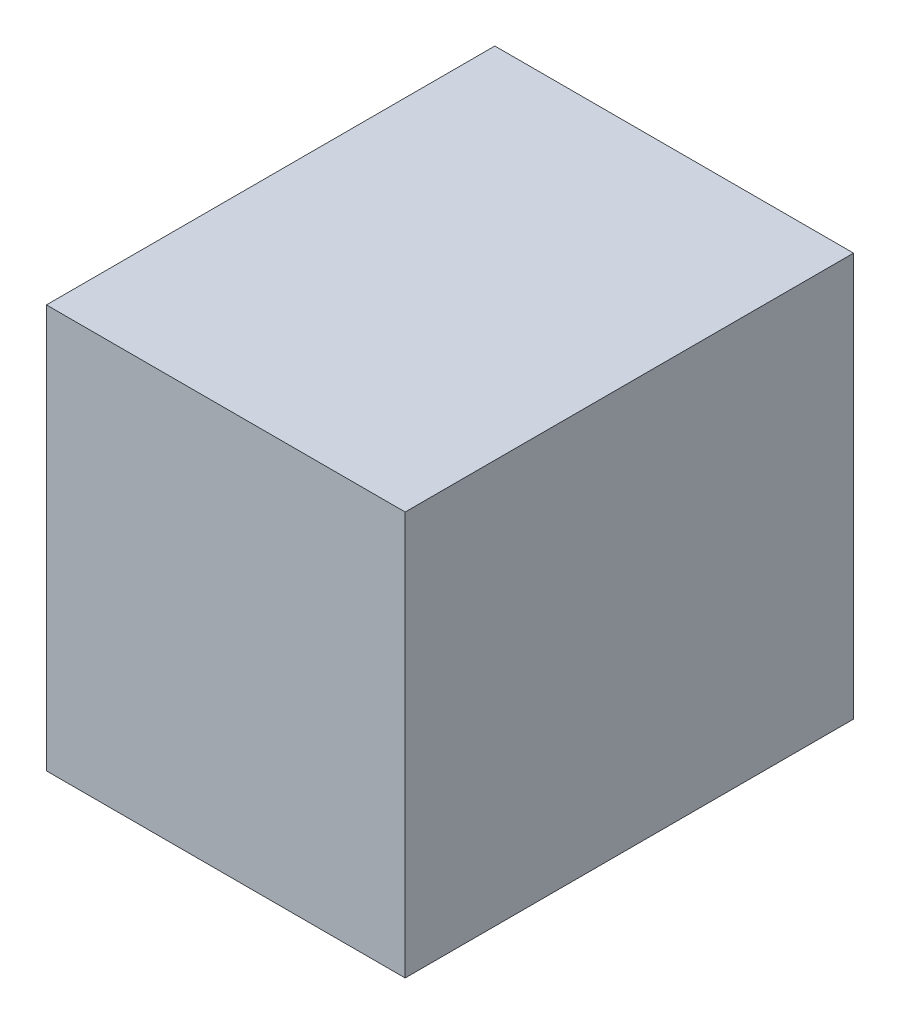
from build123d import *

# Parameters (mm, degrees)
SKETCH1_W      = 80
SKETCH1_H      = 100
EXTRUDE1_DEPTH = 90


with BuildPart() as part:
    # Sketch1 → Extrude1 (new body)
    with BuildSketch(Plane(origin=(0, 0, 0), x_dir=(1, 0, 0), z_dir=(0, 1, 0))):
        with Locations((-40, 50)):
            Rectangle(SKETCH1_W, SKETCH1_H)
    extrude(amount=EXTRUDE1_DEPTH)


solid = part.part
